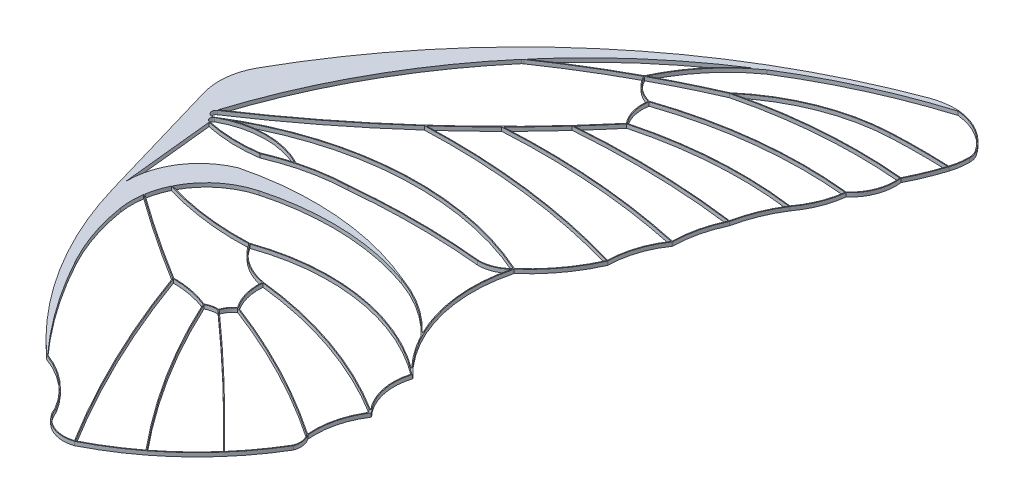
from build123d import *

# Parameters (mm, degrees)
RESSALTO_EXTRUS_O1_DEPTH = 2


with BuildPart() as part:
    # Esboço1 → Ressalto-extrusão1 (new body)
    with BuildSketch(Plane(origin=(0, 0, 0), x_dir=(1, 0, 0), z_dir=(0, 1, 0))):
        with BuildLine():
            Line((16.890636414, -92.871950666), (-2.891885916, -25.331386579))
            ThreePointArc((-2.891885916, -25.331386579), (-4.004170085, -12.373640544), (0, 0))
            ThreePointArc((0, 0), (80.341988523, 97.826401656), (189.397159866, 162.105555232))
            ThreePointArc((189.397159866, 162.105555232), (196.305976757, 163.870755082), (203.432149719, 164.126372503))
            ThreePointArc((203.432149719, 164.126372503), (216.132997815, 159.854580332), (225.805048795, 150.58035904))
            ThreePointArc((225.805048795, 150.58035904), (226.92415432, 148.202079294), (227.308114084, 145.601851107))
            ThreePointArc((227.308114084, 145.601851107), (226.936116515, 140.796582456), (225.828988219, 136.105819626))
            ThreePointArc((225.828988219, 136.105819626), (222.53357195, 127.064851642), (218.517613108, 118.320084919))
            ThreePointArc((218.517613108, 118.320084919), (217.157138995, 106.918422119), (210.665701384, 97.446883587))
            ThreePointArc((210.665701384, 97.446883587), (207.81407221, 86.384811826), (202.212176332, 76.428909901))
            ThreePointArc((202.212176332, 76.428909901), (196.683977717, 65.597702677), (193.192392505, 53.949318131))
            ThreePointArc((193.192392505, 53.949318131), (193.186037336, 53.925638832), (193.176832614, 53.902915046))
            ThreePointArc((193.176832614, 53.902915046), (189.041723719, 42.177149), (187.495240153, 29.840167866))
            ThreePointArc((187.495240153, 29.840167866), (187.463240561, 29.647364474), (187.376766076, 29.472095295))
            ThreePointArc((187.376766076, 29.472095295), (181.421355488, 17.384501121), (179.237322945, 4.087627428))
            ThreePointArc((179.237322945, 4.087627428), (179.232638679, 4.047550287), (179.220005433, 4.009229005))
            ThreePointArc((179.220005433, 4.009229005), (170.345122282, -11.218617872), (158.407910237, -24.186032419))
            ThreePointArc((158.407910237, -24.186032419), (158.838253644, -64.171647637), (179.513294894, -98.399958861))
            ThreePointArc((179.513294894, -98.399958861), (179.568845143, -98.494180052), (179.566523634, -98.60353303))
            ThreePointArc((179.566523634, -98.60353303), (179.033051629, -113.383903181), (185.969624565, -126.446364285))
            ThreePointArc((185.969624565, -126.446364285), (186.089619632, -126.716123165), (186.018022228, -127.002553753))
            ThreePointArc((186.018022228, -127.002553753), (180.544757753, -139.671656891), (179.579203123, -153.438664648))
            ThreePointArc((179.579203123, -153.438664648), (181.188239019, -157.584851871), (180.732122887, -162.008857192))
            ThreePointArc((180.732122887, -162.008857192), (155.03526296, -193.949101447), (121.431473842, -217.428734539))
            ThreePointArc((121.431473842, -217.428734539), (121.423131136, -217.432766567), (121.414649078, -217.436496537))
            ThreePointArc((121.414649078, -217.436496537), (109.339932134, -216.703217601), (101.317198447, -207.649365854))
            ThreePointArc((101.317198447, -207.649365854), (90.053250325, -194.317508541), (74.924632392, -185.614643143))
            ThreePointArc((74.924632392, -185.614643143), (39.509715195, -143.24681252), (16.890636414, -92.871950666))
        make_face()
        with BuildLine():
            Line((11.85931196, -37.464698075), (16.890636414, -86.132821))
            ThreePointArc((16.890636414, -86.132821), (23.057242833, -64.675979535), (40.261886529, -50.448424731))
            ThreePointArc((40.261886529, -50.448424731), (87.670250354, -46.538605901), (133.842737694, -57.981553802))
            ThreePointArc((133.842737694, -57.981553802), (149.854946418, -65.924493525), (163.541497745, -77.420555131))
            ThreePointArc((163.541497745, -77.420555131), (155.983137797, -51.598831019), (157.848232778, -24.758345519))
            ThreePointArc((157.848232778, -24.758345519), (151.973262614, -28.636570967), (145.058243072, -29.955059416))
            ThreePointArc((145.058243072, -29.955059416), (111.045550918, -28.261906009), (77.032122973, -29.940213308))
            ThreePointArc((77.032122973, -29.940213308), (57.801285112, -32.389959226), (39.361189646, -38.372371707))
            ThreePointArc((39.361189646, -38.372371707), (25.569939965, -39.139925167), (11.85931196, -37.464698075))
        make_face(mode=Mode.SUBTRACT)
        with BuildLine():
            ThreePointArc((11.070359275, -33.894012744), (10.253925603, -35.789100329), (11.879579324, -37.059994062))
            ThreePointArc((11.879579324, -37.059994062), (25.524465377, -38.738184329), (39.251467246, -37.984090401))
            ThreePointArc((39.251467246, -37.984090401), (45.854920305, -35.402452346), (52.618625636, -33.275779462))
            ThreePointArc((52.618625636, -33.275779462), (31.766860679, -28.367665282), (11.070359275, -33.894012744))
        make_face(mode=Mode.SUBTRACT)
        with BuildLine():
            ThreePointArc((202.714101827, 163.712950676), (167.471686306, 150.296359156), (134.231187047, 132.489001443))
            ThreePointArc((134.231187047, 132.489001443), (117.587042911, 117.093961509), (105.366397335, 97.997087152))
            ThreePointArc((105.366397335, 97.997087152), (119.960236596, 105.436275442), (134.832810466, 112.301274588))
            ThreePointArc((134.832810466, 112.301274588), (162.992204891, 129.355762587), (195.166849247, 136.327083543))
            ThreePointArc((195.166849247, 136.327083543), (210.329945011, 136.70097858), (225.494110918, 136.373346207))
            ThreePointArc((225.494110918, 136.373346207), (226.552562533, 140.93374904), (226.908114084, 145.601851107))
            ThreePointArc((226.908114084, 145.601851107), (226.541225779, 148.086469034), (225.471877456, 150.359006698))
            ThreePointArc((225.471877456, 150.359006698), (215.925826131, 159.51241094), (203.390434406, 163.728553659))
            ThreePointArc((203.390434406, 163.728553659), (203.051769924, 163.742347016), (202.714101827, 163.712950676))
        make_face(mode=Mode.SUBTRACT)
        with BuildLine():
            ThreePointArc((39.414410112, -134.60371344), (55.710509097, -160.996401051), (75.061191815, -185.238675693))
            ThreePointArc((75.061191815, -185.238675693), (90.32477142, -194.023121535), (101.682640282, -207.482028103))
            ThreePointArc((101.682640282, -207.482028103), (109.381253065, -216.277627559), (121.038273811, -217.140805352))
            ThreePointArc((121.038273811, -217.140805352), (94.455943613, -168.678582058), (73.078069491, -117.706100627))
            ThreePointArc((73.078069491, -117.706100627), (50.023709071, -102.94081443), (27.530070276, -87.334616156))
            ThreePointArc((27.530070276, -87.334616156), (27.068868432, -93.446906914), (27.564899418, -99.556469804))
            ThreePointArc((27.564899418, -99.556469804), (32.024240404, -117.575549791), (39.414410112, -134.60371344))
        make_face(mode=Mode.SUBTRACT)
        with BuildLine():
            ThreePointArc((55.949990062, -55.478367997), (95.05027781, -50.955008797), (133.708809753, -58.358466666))
            ThreePointArc((133.708809753, -58.358466666), (149.927402921, -66.450957854), (163.72457307, -78.205500545))
            ThreePointArc((163.72457307, -78.205500545), (163.984765643, -78.494020984), (164.23916715, -78.787660375))
            ThreePointArc((164.23916715, -78.787660375), (169.918511042, -87.993064481), (176.841349297, -96.30382391))
            ThreePointArc((176.841349297, -96.30382391), (128.956486326, -76.690746726), (77.454382768, -81.707341939))
            ThreePointArc((77.454382768, -81.707341939), (54.053212131, -80.755434548), (31.132626071, -75.942156085))
            ThreePointArc((31.132626071, -75.942156085), (41.348809985, -63.051320172), (55.949990062, -55.478367997))
        make_face(mode=Mode.SUBTRACT)
        with BuildLine():
            ThreePointArc((8.646375466, -29.892212669), (7.936541731, -32.891512454), (10.884162093, -33.792177396))
            ThreePointArc((10.884162093, -33.792177396), (83.286903321, -10.270827271), (158.195344978, -23.840507352))
            ThreePointArc((158.195344978, -23.840507352), (169.975242199, -11.046105684), (178.761046703, 3.962969299))
            ThreePointArc((178.761046703, 3.962969299), (124.842337918, 15.064533704), (69.841232126, 17.377594644))
            ThreePointArc((69.841232126, 17.377594644), (40.102456108, -7.368908744), (8.646375466, -29.892212669))
        make_face(mode=Mode.SUBTRACT)
        with BuildLine():
            ThreePointArc((65.873725431, 73.521849244), (65.512554625, 73.261919505), (65.163327011, 72.986151676))
            ThreePointArc((65.163327011, 72.986151676), (31.751463387, 24.609289931), (8.608266137, -29.43759531))
            ThreePointArc((8.608266137, -29.43759531), (68.727790014, 16.919047723), (121.642967981, 71.355060116))
            ThreePointArc((121.642967981, 71.355060116), (117.855262612, 78.759779692), (117.42803317, 87.066045938))
            ThreePointArc((117.42803317, 87.066045938), (110.028306452, 90.798172973), (104.841521177, 97.262071658))
            ThreePointArc((104.841521177, 97.262071658), (85.034977645, 85.921559119), (65.873725431, 73.521849244))
        make_face(mode=Mode.SUBTRACT)
        with BuildLine():
            ThreePointArc((104.7762631, 97.681029789), (115.574418721, 115.248461285), (130.105906511, 129.878932118))
            ThreePointArc((130.105906511, 129.878932118), (96.177838084, 104.381251589), (66.264337516, 74.274308482))
            ThreePointArc((66.264337516, 74.274308482), (85.206415837, 86.494114614), (104.7762631, 97.681029789))
        make_face(mode=Mode.SUBTRACT)
        with BuildLine():
            ThreePointArc((135.713472408, 112.526537053), (163.518917342, 129.134060421), (195.18595438, 135.927540062))
            ThreePointArc((195.18595438, 135.927540062), (210.276471462, 136.300892078), (225.368164637, 135.97856519))
            ThreePointArc((225.368164637, 135.97856519), (222.128079781, 127.130596632), (218.195023717, 118.568133932))
            ThreePointArc((218.195023717, 118.568133932), (176.701785201, 118.994028297), (135.713472408, 112.526537053))
        make_face(mode=Mode.SUBTRACT)
        with BuildLine():
            ThreePointArc((135.00518658, 111.940090583), (176.305917901, 118.563594016), (218.132560685, 118.172238852))
            ThreePointArc((218.132560685, 118.172238852), (216.767534509, 107.01891476), (210.409374715, 97.754264805))
            ThreePointArc((210.409374715, 97.754264805), (163.467402557, 97.622974649), (117.64681506, 87.422986968))
            ThreePointArc((117.64681506, 87.422986968), (110.323017386, 91.074314456), (105.194171334, 97.451237144))
            ThreePointArc((105.194171334, 97.451237144), (119.956691333, 104.989862866), (135.00518658, 111.940090583))
        make_face(mode=Mode.SUBTRACT)
        with BuildLine():
            ThreePointArc((121.975723187, 71.579960434), (118.238216137, 78.876060323), (117.832890254, 87.063718319))
            ThreePointArc((117.832890254, 87.063718319), (163.48468813, 97.222424933), (210.25288905, 97.368547957))
            ThreePointArc((210.25288905, 97.368547957), (207.439428108, 86.525283804), (201.957251989, 76.756062495))
            ThreePointArc((201.957251989, 76.756062495), (161.711502037, 78.108067884), (121.975723187, 71.579960434))
        make_face(mode=Mode.SUBTRACT)
        with BuildLine():
            ThreePointArc((201.712469543, 76.384918569), (196.290949467, 65.692265225), (192.837884131, 54.211757605))
            ThreePointArc((192.837884131, 54.211757605), (151.026567478, 57.488322955), (109.101297358, 56.395708613))
            ThreePointArc((109.101297358, 56.395708613), (115.62650859, 63.726667144), (122.015582584, 71.176571043))
            ThreePointArc((122.015582584, 71.176571043), (161.60786351, 77.700482874), (201.712469543, 76.384918569))
        make_face(mode=Mode.SUBTRACT)
        with BuildLine():
            ThreePointArc((187.097186474, 29.949540999), (139.348979985, 36.992165146), (91.086670247, 37.481283297))
            ThreePointArc((91.086670247, 37.481283297), (100.008574142, 46.616810225), (108.708987791, 55.963522143))
            ThreePointArc((108.708987791, 55.963522143), (150.759305033, 57.095075342), (192.697680535, 53.826703734))
            ThreePointArc((192.697680535, 53.826703734), (188.632596088, 42.184795574), (187.097186474, 29.949540999))
        make_face(mode=Mode.SUBTRACT)
        with BuildLine():
            ThreePointArc((70.307334653, 17.795498029), (125.114397795, 15.433974602), (178.842127699, 4.355978275))
            ThreePointArc((178.842127699, 4.355978275), (181.056540683, 17.556695855), (186.958653653, 29.570339432))
            ThreePointArc((186.958653653, 29.570339432), (139.066008112, 36.613044124), (90.660333167, 37.055558956))
            ThreePointArc((90.660333167, 37.055558956), (80.610470403, 27.291705844), (70.307334653, 17.795498029))
        make_face(mode=Mode.SUBTRACT)
        with BuildLine():
            ThreePointArc((53.184593307, -33.120484), (34.997673911, -28.037667048), (16.344111956, -30.977682642))
            ThreePointArc((16.344111956, -30.977682642), (86.294442644, -10.497166778), (157.8926845, -24.142387796))
            ThreePointArc((157.8926845, -24.142387796), (152.04587989, -28.173512381), (145.079823263, -29.555230382))
            ThreePointArc((145.079823263, -29.555230382), (111.043124536, -27.861905479), (77.00571445, -29.540870677))
            ThreePointArc((77.00571445, -29.540870677), (64.991382888, -30.640116345), (53.184593307, -33.120484))
        make_face(mode=Mode.SUBTRACT)
        with BuildLine():
            ThreePointArc((77.385630644, -82.110602151), (53.928434843, -81.142970387), (30.954862617, -76.306512457))
            ThreePointArc((30.954862617, -76.306512457), (28.904488661, -81.471516217), (27.604076284, -86.874314091))
            ThreePointArc((27.604076284, -86.874314091), (27.640126359, -86.915622588), (27.682018255, -86.950993041))
            ThreePointArc((27.682018255, -86.950993041), (50.20912985, -102.583681626), (73.29906303, -117.372417034))
            ThreePointArc((73.29906303, -117.372417034), (83.327149533, -118.337154453), (92.986045613, -121.200537717))
            ThreePointArc((92.986045613, -121.200537717), (96.035057019, -120.070400422), (99.274681475, -119.790196472))
            ThreePointArc((99.274681475, -119.790196472), (100.839320134, -116.575545142), (103.329588684, -114.010269354))
            ThreePointArc((103.329588684, -114.010269354), (99.325868559, -105.523547237), (98.476067628, -96.178384559))
            ThreePointArc((98.476067628, -96.178384559), (86.442113829, -91.376407189), (77.385630644, -82.110602151))
        make_face(mode=Mode.SUBTRACT)
        with BuildLine():
            ThreePointArc((77.796430253, -82.0108729), (130.390825581, -77.316445759), (178.842177575, -98.308695665))
            ThreePointArc((178.842177575, -98.308695665), (179.042636723, -98.592893915), (179.048514046, -98.940626531))
            ThreePointArc((179.048514046, -98.940626531), (178.557910182, -113.090704042), (184.838939896, -125.779835275))
            ThreePointArc((184.838939896, -125.779835275), (143.48611956, -105.890223927), (98.718726209, -95.813871314))
            ThreePointArc((98.718726209, -95.813871314), (86.794460768, -91.13013492), (77.796430253, -82.0108729))
        make_face(mode=Mode.SUBTRACT)
        with BuildLine():
            ThreePointArc((103.734386544, -113.889234988), (99.732427529, -105.493744387), (98.872883702, -96.233014243))
            ThreePointArc((98.872883702, -96.233014243), (143.098520561, -106.179072223), (183.998274189, -125.724945907))
            ThreePointArc((183.998274189, -125.724945907), (184.88113455, -126.943403006), (184.664770288, -128.432451905))
            ThreePointArc((184.664770288, -128.432451905), (179.978340813, -140.338043697), (179.145908385, -153.10569005))
            ThreePointArc((179.145908385, -153.10569005), (142.589295312, -131.287701646), (103.734386544, -113.889234988))
        make_face(mode=Mode.SUBTRACT)
        with BuildLine():
            ThreePointArc((99.649253017, -119.933520799), (101.18300434, -116.782199542), (103.6372122, -114.280183841))
            ThreePointArc((103.6372122, -114.280183841), (142.598272069, -131.743297777), (179.242488543, -153.655073914))
            ThreePointArc((179.242488543, -153.655073914), (180.78822356, -157.611813736), (180.367828424, -161.838911403))
            ThreePointArc((180.367828424, -161.838911403), (173.27117969, -172.652799603), (165.237327428, -182.789851396))
            ThreePointArc((165.237327428, -182.789851396), (133.00300151, -150.777649689), (99.649253017, -119.933520799))
        make_face(mode=Mode.SUBTRACT)
        with BuildLine():
            ThreePointArc((93.258837749, -121.508897014), (96.210985678, -120.441238679), (99.340524238, -120.194135217))
            ThreePointArc((99.340524238, -120.194135217), (132.717797326, -151.058354618), (164.973783051, -183.092614136))
            ThreePointArc((164.973783051, -183.092614136), (155.156655203, -193.286781209), (144.390735312, -202.473293628))
            ThreePointArc((144.390735312, -202.473293628), (116.188479484, -163.656017033), (93.258837749, -121.508897014))
        make_face(mode=Mode.SUBTRACT)
        with BuildLine():
            ThreePointArc((121.414649077, -216.988884436), (133.074913856, -210.37840662), (144.073565841, -202.71747677))
            ThreePointArc((144.073565841, -202.71747677), (115.816888065, -163.816723913), (92.849554804, -121.576813702))
            ThreePointArc((92.849554804, -121.576813702), (83.369797481, -118.753083082), (73.527113878, -117.772862193))
            ThreePointArc((73.527113878, -117.772862193), (94.877808499, -168.632444086), (121.414649077, -216.988884436))
        make_face(mode=Mode.SUBTRACT)
    extrude(amount=RESSALTO_EXTRUS_O1_DEPTH)


solid = part.part
